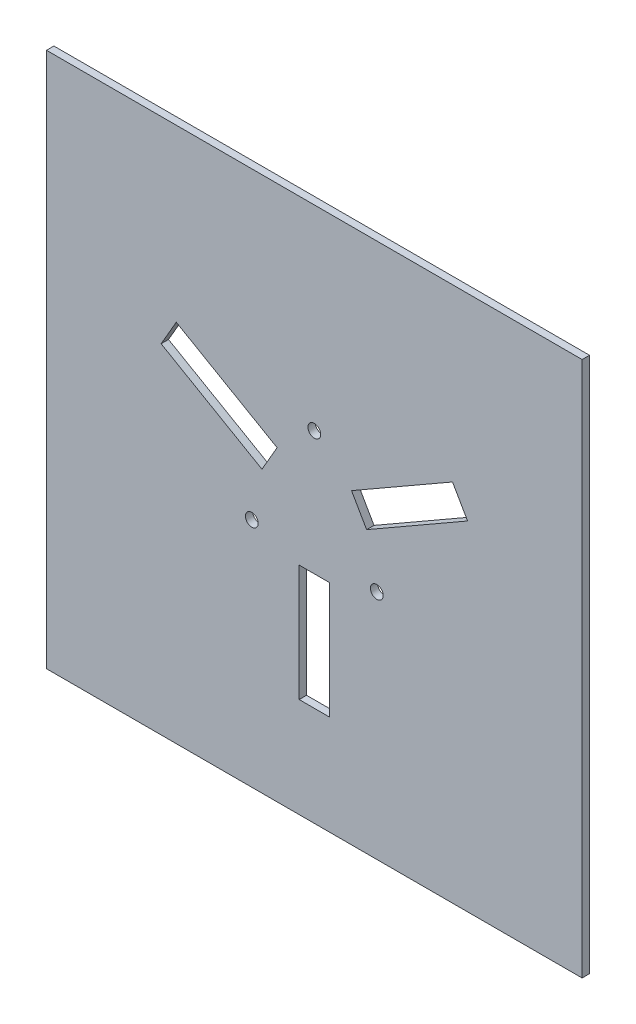
from build123d import *

# Parameters (mm, degrees)
SKETCH1_W           = 230
SKETCH1_H           = 230
SKETCH1_R           = 2.75
SKETCH1_W_2         = 13
SKETCH1_H_2         = 49.999466707
BOSS_EXTRUDE1_DEPTH = 3.175


with BuildPart() as part:
    # Sketch1 → Boss-Extrude1 (new body)
    with BuildSketch(Plane.XY.offset(3.175)):
        Rectangle(SKETCH1_W, SKETCH1_H)
        with Locations((-26.847424973, -15.500368035)):
            Circle(SKETCH1_R, mode=Mode.SUBTRACT)
        with Locations((26.847424973, -15.500368035)):
            Circle(SKETCH1_R, mode=Mode.SUBTRACT)
        with Locations((0, 31.00073607)):
            Circle(SKETCH1_R, mode=Mode.SUBTRACT)
        with Locations((0, -47.199733354)):
            Rectangle(SKETCH1_W_2, SKETCH1_H_2, mode=Mode.SUBTRACT)
        Polygon((15.988970715, 16.736769417), (59.348272994, 41.634913462), (65.821859492, 30.361374627), (22.462557213, 5.463230583), align=None, mode=Mode.SUBTRACT)
        Polygon((-65.776572308, 30.470568229), (-59.276572308, 41.728898478), (-15.975763964, 16.729165125), (-22.475763964, 5.470834875), align=None, mode=Mode.SUBTRACT)
    extrude(amount=-BOSS_EXTRUDE1_DEPTH)


solid = part.part
